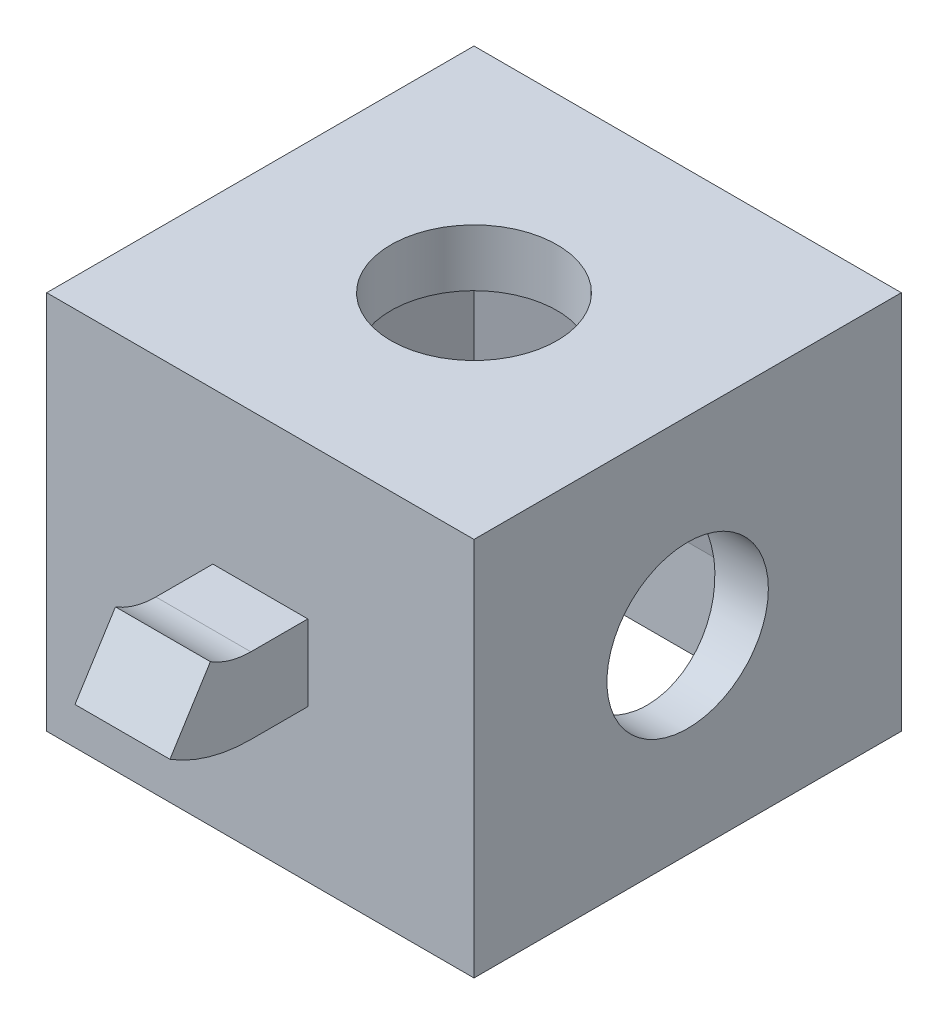
from build123d import *

# Parameters (mm, degrees)
SKETCH1_W                    = 22.5
SKETCH1_H                    = 22.5
BOSS_EXTRUDE1_DEPTH          = 20
CUT_EXTRUDE1_START           = -5
SKETCH3_W                    = 18.5
SKETCH3_H                    = 18.5
CUT_EXTRUDE1_DEPTH           = 12
CUT_EXTRUDE1_TAPER           = 10
CUT_EXTRUDE1_OTHER_WAY_DEPTH = 5
CUT_EXTRUDE2_REACH           = 22
SKETCH2_R                    = 4.375
CUT_EXTRUDE3_REACH           = 24.5
SKETCH4_R                    = 4.25
SKETCH5_W                    = 5
SKETCH5_H                    = 4


with BuildPart() as part:
    # Sketch1 → Boss-Extrude1 (new body)
    with BuildSketch(Plane(origin=(0, 0, 0), x_dir=(1, 0, 0), z_dir=(0, 1, 0))):
        Rectangle(SKETCH1_W, SKETCH1_H)
    extrude(amount=BOSS_EXTRUDE1_DEPTH)

    # Sketch3 → Cut-Extrude1 (cut)
    with BuildSketch(Plane.XZ.offset(CUT_EXTRUDE1_START)):
        Rectangle(SKETCH3_W, SKETCH3_H)
    extrude(amount=-CUT_EXTRUDE1_DEPTH, taper=CUT_EXTRUDE1_TAPER, mode=Mode.SUBTRACT)

    # Sketch3 → Cut-Extrude1 other way (cut)
    with BuildSketch(Plane.XZ.offset(CUT_EXTRUDE1_START)):
        Rectangle(SKETCH3_W, SKETCH3_H)
    extrude(amount=CUT_EXTRUDE1_OTHER_WAY_DEPTH, mode=Mode.SUBTRACT)

    # Sketch2 → Cut-Extrude2 (cut, up to next)
    with BuildSketch(Plane(origin=(0, 20, 0), x_dir=(1, 0, 0), z_dir=(0, 1, 0)), mode=Mode.PRIVATE) as cut_extrude2_sk1:
        Circle(SKETCH2_R)
    cut_extrude2_tool1 = extrude(cut_extrude2_sk1.sketch, amount=-CUT_EXTRUDE2_REACH, mode=Mode.PRIVATE) & part.part
    add(cut_extrude2_tool1.solids().sort_by_distance((0, 20, 0))[0], mode=Mode.SUBTRACT)

    # Sketch4 → Cut-Extrude3 (cut, up to next)
    with BuildSketch(Plane(origin=(11.25, 0, 0), x_dir=(0, 0, -1), z_dir=(1, 0, 0)), mode=Mode.PRIVATE) as cut_extrude3_sk1:
        with Locations((0, 10)):
            Circle(SKETCH4_R)
    cut_extrude3_tool1 = extrude(cut_extrude3_sk1.sketch, amount=-CUT_EXTRUDE3_REACH, mode=Mode.PRIVATE) & part.part
    add(cut_extrude3_tool1.solids().sort_by_distance((11.25, 10, 0))[0], mode=Mode.SUBTRACT)

    # Sweep1: sweep along a path in Sketch6
    with BuildLine(Plane(origin=(0, 0, 0), x_dir=(0, 0, -1), z_dir=(1, 0, 0))) as sweep1_path:
        Line((11.25, 10), (14.25, 10))
        ThreePointArc((14.25, 10), (15.912838742, 10.235022349), (17.445409396, 10.921677561))
    # Sketch5 → Sweep1 (sweep)
    with BuildSketch(Plane(origin=(0, 0, -11.25), x_dir=(-1, 0, 0), z_dir=(0, 0, -1))):
        with Locations((0, 10)):
            Rectangle(SKETCH5_W, SKETCH5_H)
    sweep1 = sweep(path=sweep1_path.line)

    # Mirror1: Sweep1 across plane
    add(sweep1.mirror(Plane.XY))


solid = part.part
